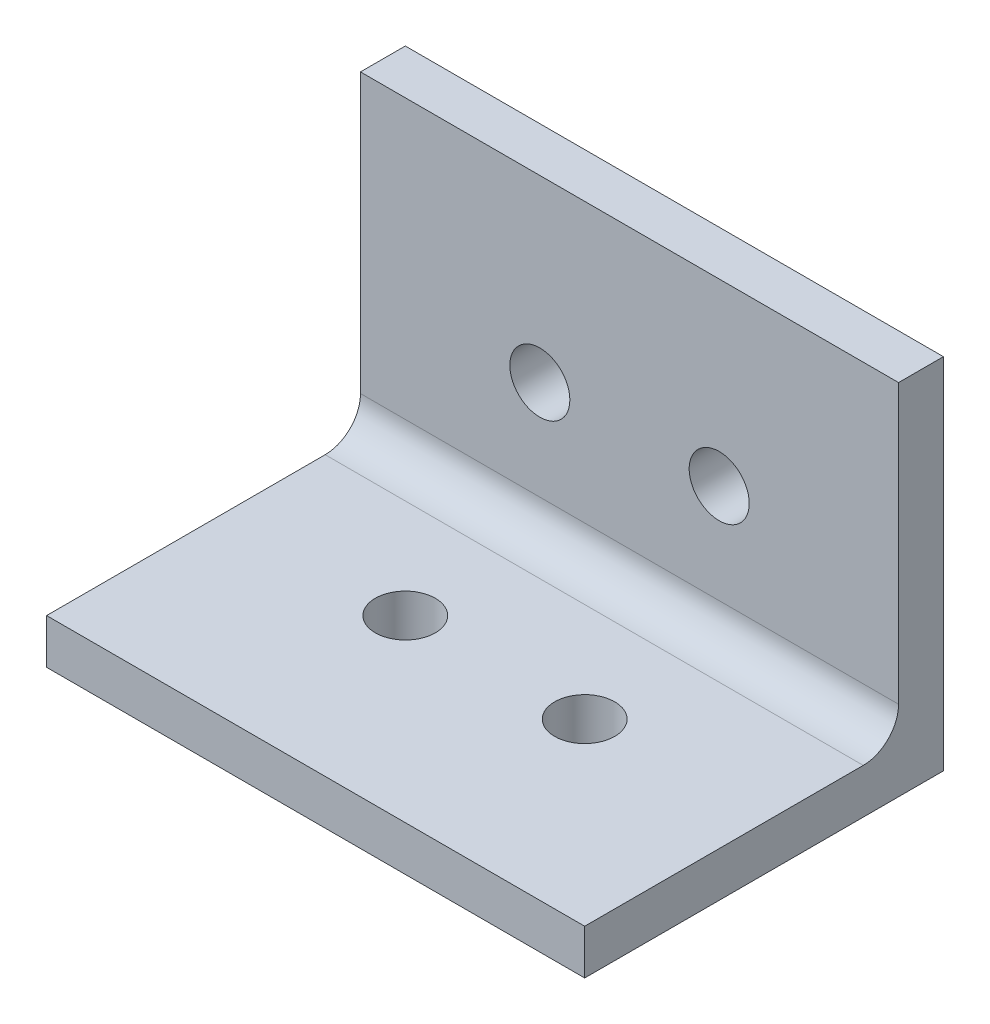
from build123d import *

# Parameters (mm, degrees)
BOSS_EXTRUDE1_DEPTH              = 76.2
TAP_DRILL_FOR_M10X1_5_TAP1_D     = 8.5
TAP_DRILL_FOR_M10X1_5_TAP2_D     = 8.5
TAP_DRILL_FOR_M10X1_5_TAP2_DEPTH = 20
TAP_DRILL_FOR_M10X1_5_TAP2_TIP   = 2.553657631
FILLET1_R                        = 5


with BuildPart() as part:
    # Sketch1 → Boss-Extrude1 (new body)
    with BuildSketch(Plane(origin=(0, 0, 0), x_dir=(0, 0, -1), z_dir=(1, 0, 0))):
        Polygon((0, 0), (0, 50.8), (-6.35, 50.8), (-6.35, 6.35), (-50.8, 6.35), (-50.8, 0), align=None)
    extrude(amount=BOSS_EXTRUDE1_DEPTH)

    # Tap Drill for M10x1.5 Tap1 (through all)
    with Locations(Plane(origin=(0, 6.35, 0), x_dir=(1, 0, 0), z_dir=(0, 1, 0))):
        with Locations((25.4, -25.4), (50.8, -25.4)):
            Hole(TAP_DRILL_FOR_M10X1_5_TAP1_D / 2)

    # Tap Drill for M10x1.5 Tap2
    with Locations(Plane.XY.offset(6.35)):
        with Locations((25.4, 25.4), (50.8, 25.4)):
            Hole(TAP_DRILL_FOR_M10X1_5_TAP2_D / 2, depth=TAP_DRILL_FOR_M10X1_5_TAP2_DEPTH)
            with Locations((0, 0, -(TAP_DRILL_FOR_M10X1_5_TAP2_DEPTH + TAP_DRILL_FOR_M10X1_5_TAP2_TIP / 2))):  # 118° drill point
                Cone(0, TAP_DRILL_FOR_M10X1_5_TAP2_D / 2, TAP_DRILL_FOR_M10X1_5_TAP2_TIP, mode=Mode.SUBTRACT)

    # Fillet1
    fillet1_edges = [part.edges().sort_by_distance(p)[0] for p in [
        (38.1, 6.35, 6.35),
    ]]
    fillet(fillet1_edges, radius=FILLET1_R)


solid = part.part
